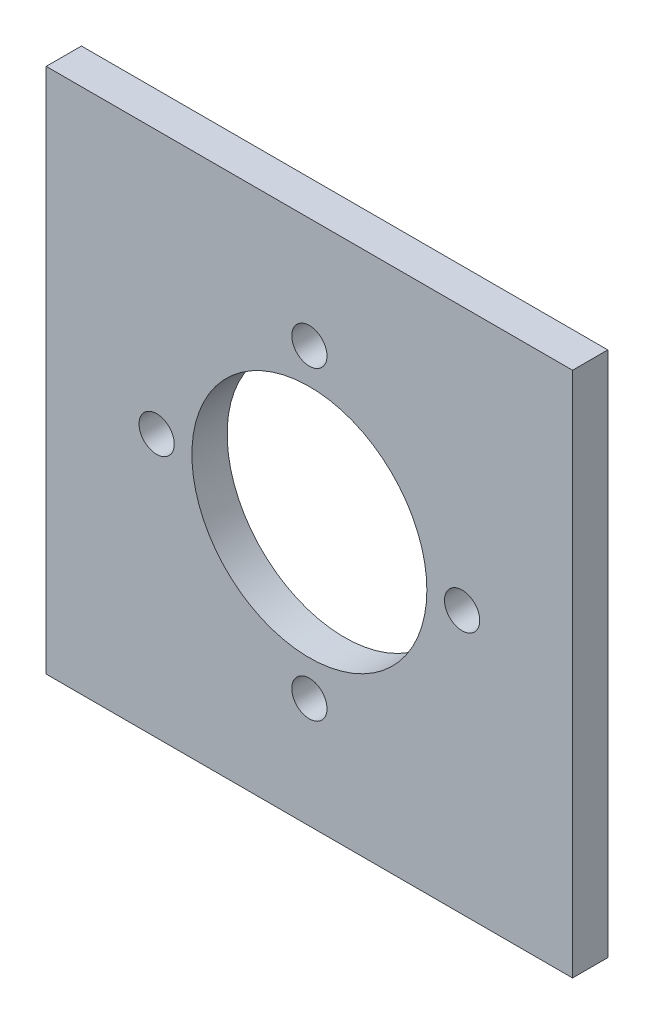
from build123d import *

# Parameters (mm, degrees)
ESQUISSE1_W             = 44.8
ESQUISSE1_H             = 44.8
BOSS_EXTRU_1_DEPTH      = 3
ESQUISSE2_R             = 1.5
ESQUISSE2_R_2           = 10
ENL_V_MAT_EXTRU_1_DEPTH = 3


with BuildPart() as part:
    # Esquisse1 → Boss.-Extru.1 (new body)
    with BuildSketch(Plane.XY):
        with Locations((-13.281904392, -0.294716352)):
            Rectangle(ESQUISSE1_W, ESQUISSE1_H)
    extrude(amount=BOSS_EXTRU_1_DEPTH)

    # Esquisse2 → Enlèv. mat.-Extru.1 (cut)
    with BuildSketch(Plane.XY.offset(3)):
        with Locations((-13.281904392, 12.705283648)):
            Circle(ESQUISSE2_R)
        with Locations((-0.281904392, -0.294716352)):
            Circle(ESQUISSE2_R)
        with Locations((-13.281904392, -13.294716352)):
            Circle(ESQUISSE2_R)
        with Locations((-26.281904392, -0.294716352)):
            Circle(ESQUISSE2_R)
        with Locations((-13.281904392, -0.294716352)):
            Circle(ESQUISSE2_R_2)
    extrude(amount=-ENL_V_MAT_EXTRU_1_DEPTH, mode=Mode.SUBTRACT)


solid = part.part
